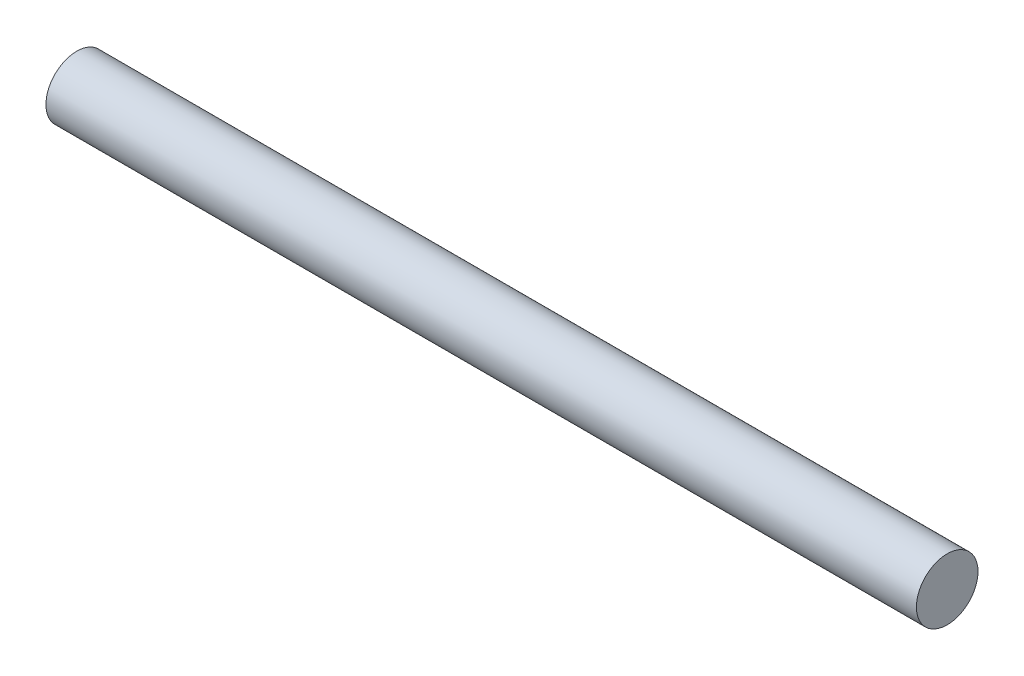
from build123d import *

# Parameters (mm, degrees)
SKETCH1_R           = 1.1684
BOSS_EXTRUDE1_DEPTH = 33.02


with BuildPart() as part:
    # Sketch1 → Boss-Extrude1 (new body)
    with BuildSketch(Plane(origin=(0, 0, 0), x_dir=(0, 0, -1), z_dir=(1, 0, 0))):
        Circle(SKETCH1_R)
    extrude(amount=BOSS_EXTRUDE1_DEPTH)


solid = part.part
